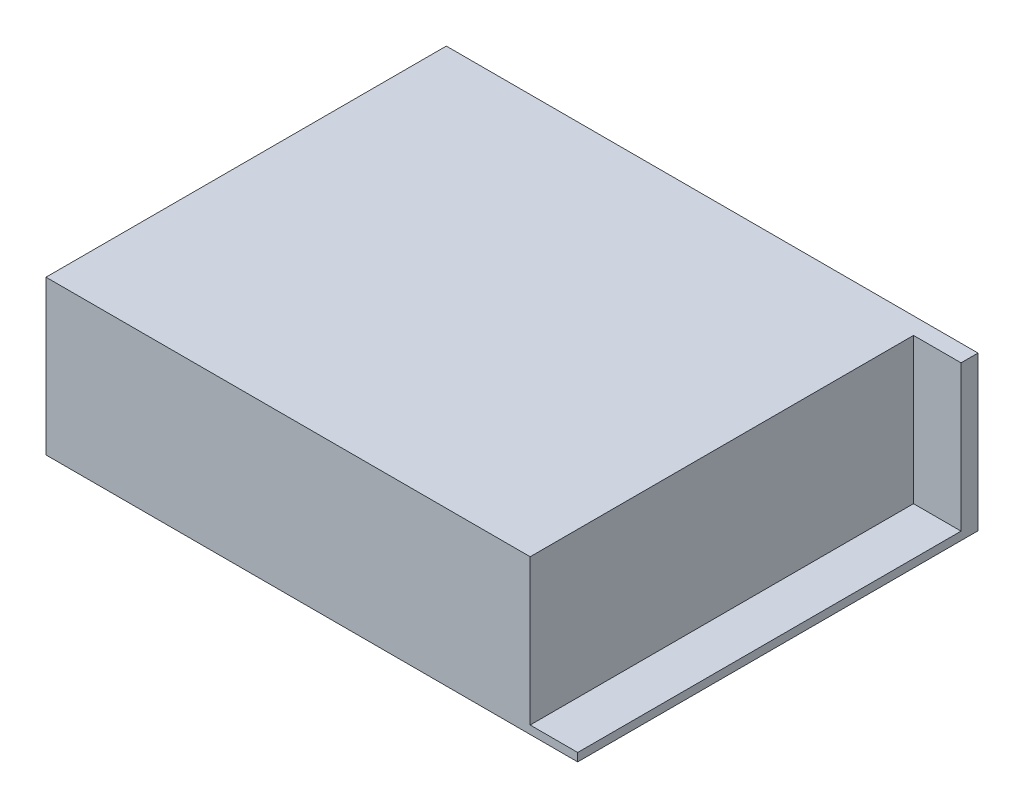
from build123d import *

# Parameters (mm, degrees)
SKETCH1_W                = 129.5
SKETCH1_H                = 97.5
BOSS_EXTRUDE1_DEPTH      = 37.5
M3_CLEARANCE_HOLE1_D     = 3.4
M3_CLEARANCE_HOLE1_DEPTH = 0.737
M3_CLEARANCE_HOLE1_TIP   = 1.021463052
SKETCH5_W                = 11.575237046
SKETCH5_H                = 93.370280938
CUT_EXTRUDE1_DEPTH       = 35.5


with BuildPart() as part:
    # Sketch1 → Boss-Extrude1 (new body)
    with BuildSketch(Plane(origin=(0, 0, 0), x_dir=(1, 0, 0), z_dir=(0, 1, 0))):
        with Locations((64.75, 48.75)):
            Rectangle(SKETCH1_W, SKETCH1_H)
    extrude(amount=BOSS_EXTRUDE1_DEPTH)

    # M3 Clearance Hole1
    with Locations(Plane(origin=(0, 0, 0), x_dir=(-1, 0, 0), z_dir=(0, -1, 0))):
        with Locations((-51.5, 63.75), (-51.5, 30.75)):
            Hole(M3_CLEARANCE_HOLE1_D / 2, depth=M3_CLEARANCE_HOLE1_DEPTH)
            with Locations((0, 0, -(M3_CLEARANCE_HOLE1_DEPTH + M3_CLEARANCE_HOLE1_TIP / 2))):  # 118° drill point
                Cone(0, M3_CLEARANCE_HOLE1_D / 2, M3_CLEARANCE_HOLE1_TIP, mode=Mode.SUBTRACT)

    # Sketch5 → Cut-Extrude1 (cut)
    with BuildSketch(Plane(origin=(0, 37.5, 0), x_dir=(1, 0, 0), z_dir=(0, 1, 0))):
        with Locations((123.712381477, 46.685140469)):
            Rectangle(SKETCH5_W, SKETCH5_H)
    extrude(amount=-CUT_EXTRUDE1_DEPTH, mode=Mode.SUBTRACT)


solid = part.part
